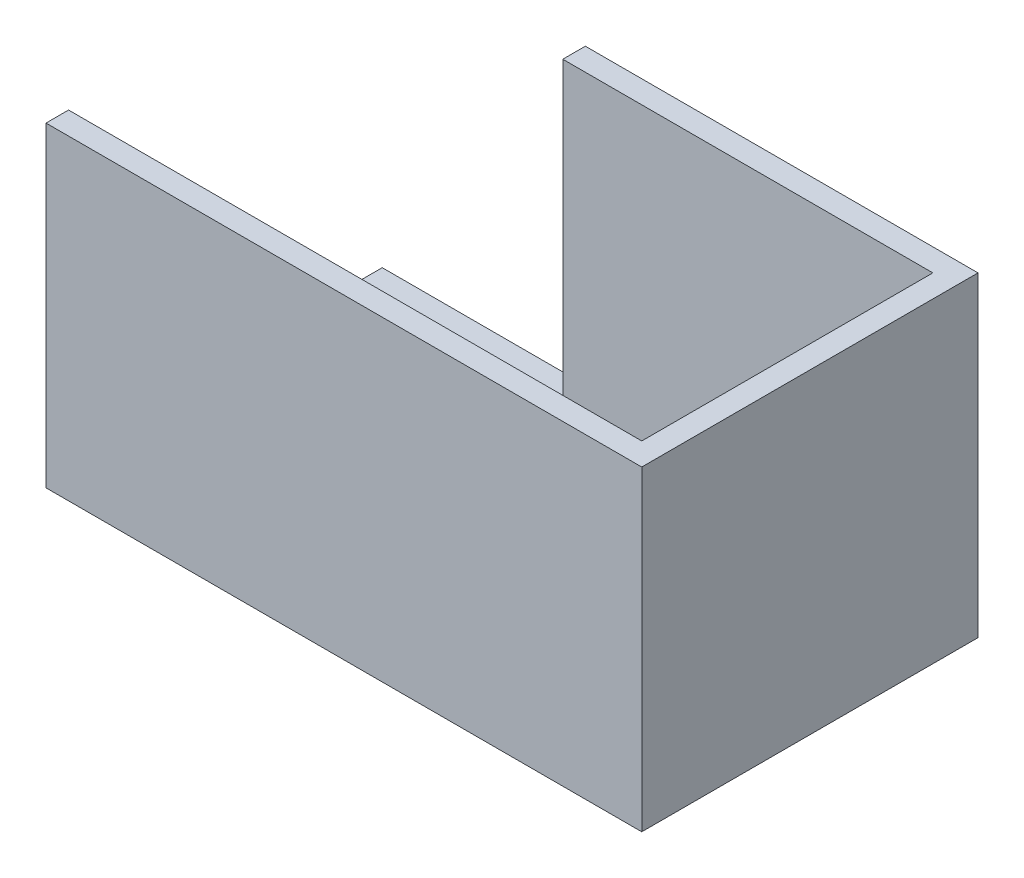
from build123d import *

# Parameters (mm, degrees)
SKETCH1_W           = 52.8
SKETCH1_H           = 29.8
BOSS_EXTRUDE1_DEPTH = 2
BOSS_EXTRUDE2_DEPTH = 26


with BuildPart() as part:
    # Sketch1 → Boss-Extrude1 (new body)
    with BuildSketch(Plane(origin=(0, 0, 0), x_dir=(1, 0, 0), z_dir=(0, 1, 0))):
        with Locations((26.4, -14.9)):
            Rectangle(SKETCH1_W, SKETCH1_H)
    extrude(amount=BOSS_EXTRUDE1_DEPTH)

    # Sketch2 → Boss-Extrude2 (add)
    with BuildSketch(Plane(origin=(0, 2, 0), x_dir=(1, 0, 0), z_dir=(0, 1, 0))):
        Polygon((0, -27.8), (0, -29.8), (52.8, -29.8), (52.8, 0), (18, 0), (18, -2), (50.8, -2), (50.8, -27.8), align=None)
    extrude(amount=BOSS_EXTRUDE2_DEPTH)


solid = part.part
